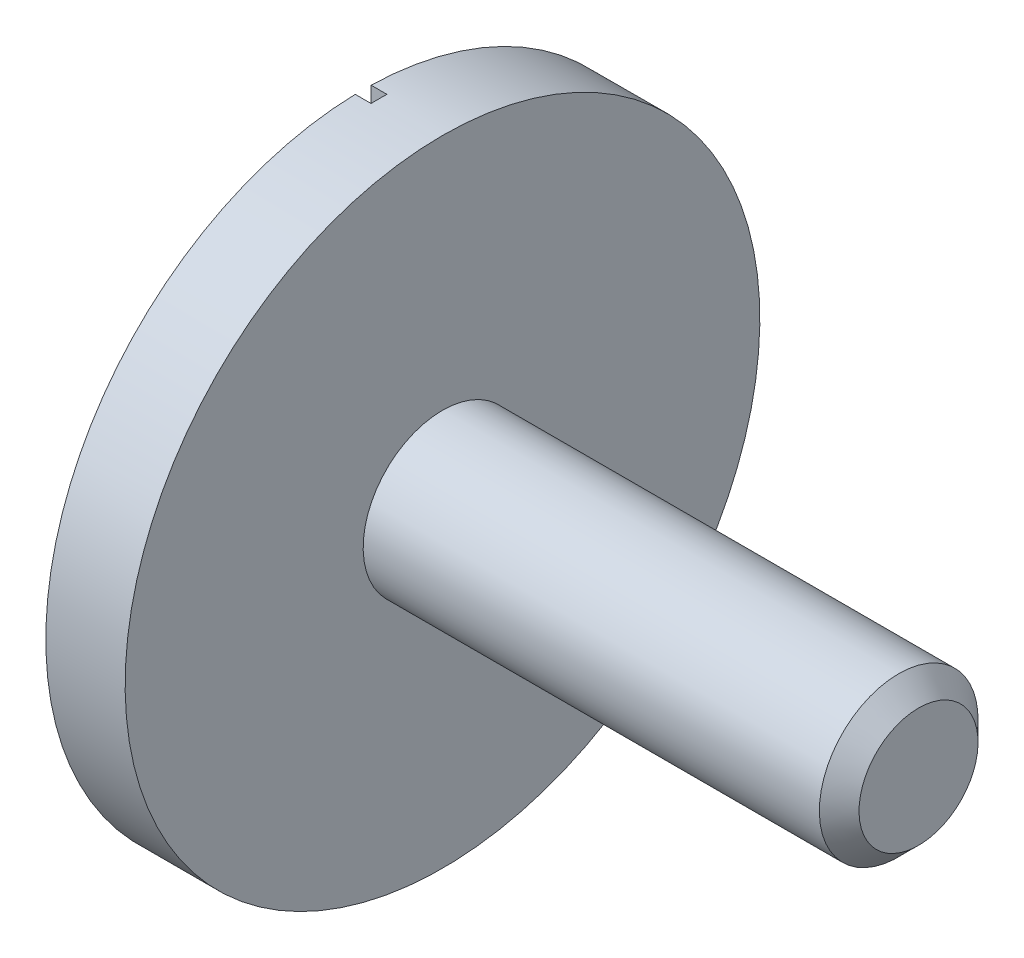
from build123d import *

# Parameters (mm, degrees)
CHAFL_N1_SIZE         = 0.125
CORTAR_EXTRUIR2_DEPTH = 0.1


with BuildPart() as part:
    # Croquis1 → Revolución1 (revolve)
    with BuildSketch(Plane.XY):
        Polygon((0, 0), (0, 2), (0.5, 2), (0.5, 0.5), (3.5, 0.5), (3.5, 0), align=None)
    revolve(axis=Axis((3.5, 0, 0), (-1, 0, 0)))

    # Chaflán1
    chafl_n1_edges = [part.edges().sort_by_distance(p)[0] for p in [
        (3.5, -0.5, 0),
    ]]
    chamfer(chafl_n1_edges, length=CHAFL_N1_SIZE)

    # Croquis6 → Cortar-Extruir2 (cut)
    with BuildSketch(Plane.ZY):
        with BuildLine():
            Line((-0.05, 1.999374902), (-0.05, -1.999374902))
            ThreePointArc((-0.05, -1.999374902), (0, -2), (0.05, -1.999374902))
            Line((0.05, -1.999374902), (0.05, 1.999374902))
            ThreePointArc((0.05, 1.999374902), (0, 2), (-0.05, 1.999374902))
        make_face()
    extrude(amount=-CORTAR_EXTRUIR2_DEPTH, mode=Mode.SUBTRACT)


solid = part.part
